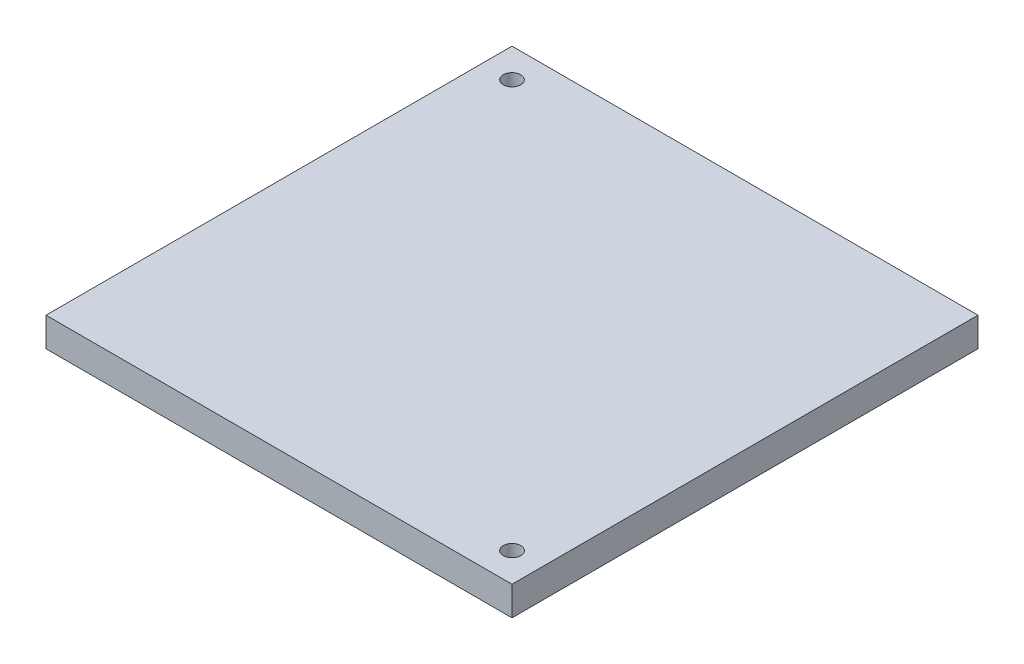
from build123d import *

# Parameters (mm, degrees)
ESQUISSE1_W             = 80
ESQUISSE1_H             = 80
BOSS_EXTRU_1_DEPTH      = 5
ESQUISSE2_R             = 1.5
ENL_V_MAT_EXTRU_1_DEPTH = 6


with BuildPart() as part:
    # Esquisse1 → Boss.-Extru.1 (new body)
    with BuildSketch(Plane(origin=(0, 0, 0), x_dir=(1, 0, 0), z_dir=(0, 1, 0))):
        Rectangle(ESQUISSE1_W, ESQUISSE1_H)
    extrude(amount=BOSS_EXTRU_1_DEPTH)

    # Esquisse2 → Enlèv. mat.-Extru.1 (cut, through all)
    with BuildSketch(Plane(origin=(0, 5, 0), x_dir=(1, 0, 0), z_dir=(0, 1, 0))):
        with Locations((-35, 35)):
            Circle(ESQUISSE2_R)
        with Locations((35, -35)):
            Circle(ESQUISSE2_R)
    extrude(amount=-ENL_V_MAT_EXTRU_1_DEPTH, mode=Mode.SUBTRACT)


solid = part.part
